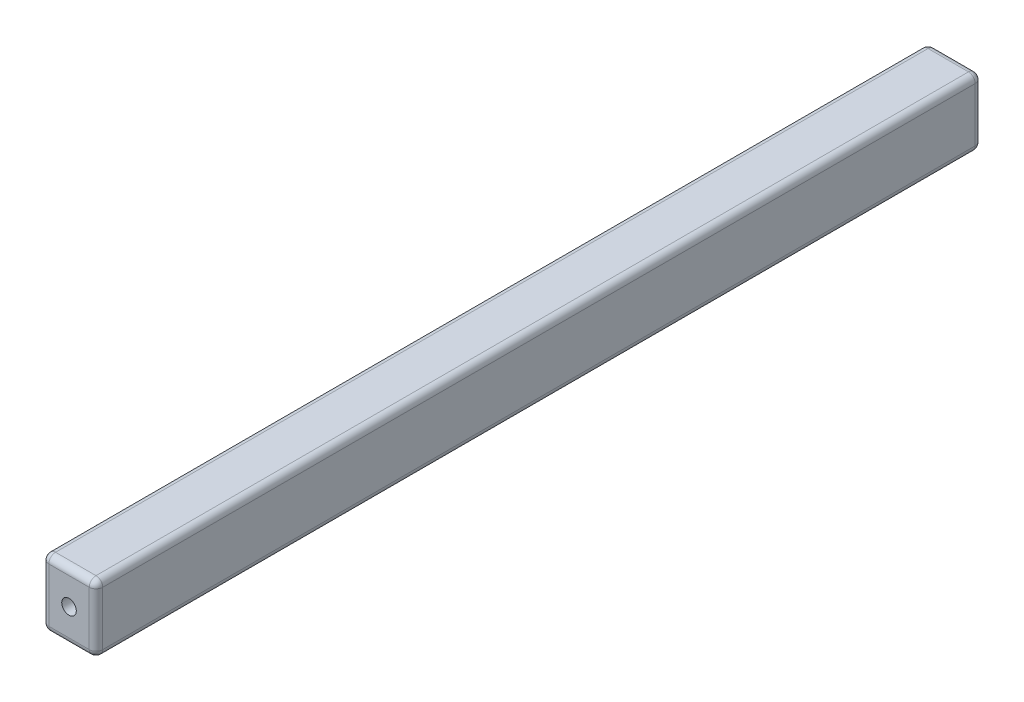
from build123d import *

# Parameters (mm, degrees)
CROQUIS1_W              = 40
CROQUIS1_H              = 50
SALIENTE_EXTRUIR1_DEPTH = 328.45
REDONDEO1_R             = 5


with BuildPart() as part:
    # Croquis1 → Saliente-Extruir1 (new body, symmetric)
    with BuildSketch(Plane.XY):
        Rectangle(CROQUIS1_W, CROQUIS1_H)
    extrude(amount=SALIENTE_EXTRUIR1_DEPTH, both=True)

    # Redondeo1
    redondeo1_edges = [part.edges().sort_by_distance(p)[0] for p in [
        (20, 0, 328.45),
        (0, 25, 328.45),
        (-20, 0, 328.45),
        (0, 25, -328.45),
        (20, 0, -328.45),
        (0, -25, -328.45),
        (-20, 0, -328.45),
        (-20, 25, 0),
        (20, 25, 0),
        (20, -25, 0),
        (-20, -25, 0),
        (0, -25, 328.45),
    ]]
    fillet(redondeo1_edges, radius=REDONDEO1_R)

    # Croquis3 → Taladro roscado M12x1.251 (revolve, cut)
    with BuildSketch(Plane(origin=(0, 0, 328.45), x_dir=(0, -1, 0), z_dir=(1, 0, 0))):
        Polygon((0, 0), (0, 13.244647343), (5.4, 10), (5.4, 0), align=None)
    taladro_roscado_m12x1_251 = revolve(axis=Axis((0, 0, 334.8), (0, 0, -1)), mode=Mode.SUBTRACT)

    # Simetría1: Taladro roscado M12x1.251 across plane
    add(taladro_roscado_m12x1_251.mirror(Plane.XY), mode=Mode.SUBTRACT)


solid = part.part
